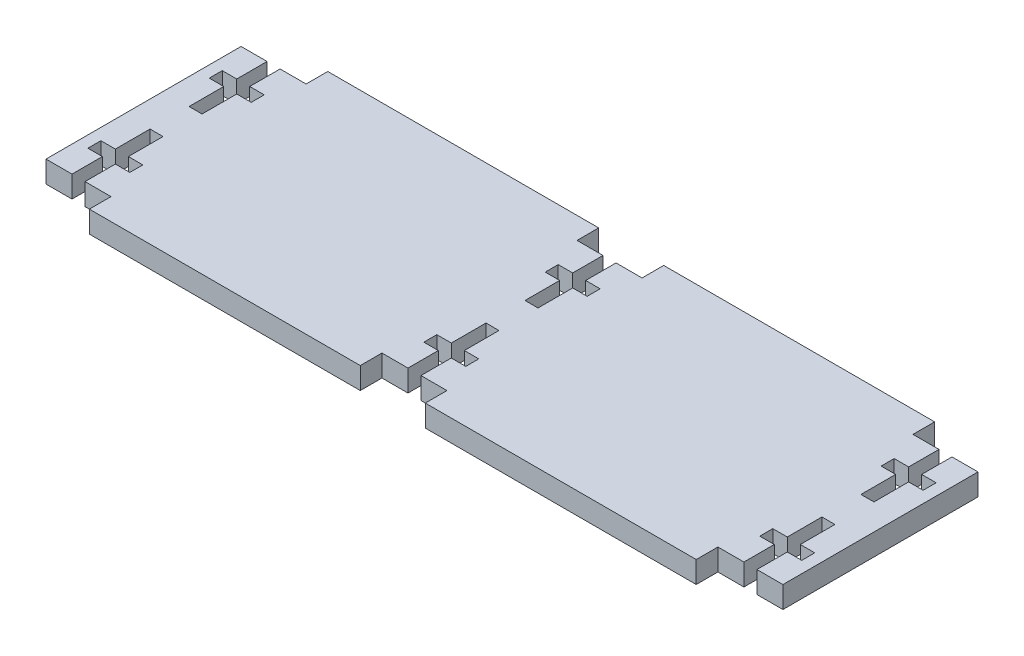
from build123d import *

# Parameters (mm, degrees)
SCHIZZO1_W                   = 170
SCHIZZO1_H                   = 55
ESTRUSIONE_ESTRUSIONE2_DEPTH = 5
SCHIZZO2_W                   = 15
SCHIZZO2_H                   = 5
TAGLIO_ESTRUSIONE1_DEPTH     = 6
TAGLIO_ESTRUSIONE3_DEPTH     = 6


with BuildPart() as part:
    # Schizzo1 → Estrusione-Estrusione2 (new body)
    with BuildSketch(Plane(origin=(0, 0, 0), x_dir=(1, 0, 0), z_dir=(0, 1, 0))):
        with Locations((30.43505086, -0.781075862)):
            Rectangle(SCHIZZO1_W, SCHIZZO1_H)
    extrude(amount=-ESTRUSIONE_ESTRUSIONE2_DEPTH)

    # Schizzo2 → Taglio-Estrusione1 (cut, through all)
    with BuildSketch(Plane(origin=(0, 0, 0), x_dir=(1, 0, 0), z_dir=(0, 1, 0))):
        with Locations((-47.06494914, -25.781075862)):
            Rectangle(SCHIZZO2_W, SCHIZZO2_H)
        with Locations((-47.06494914, 24.218924138)):
            Rectangle(SCHIZZO2_W, SCHIZZO2_H)
        with Locations((107.93505086, -25.781075862)):
            Rectangle(SCHIZZO2_W, SCHIZZO2_H)
        with Locations((107.93505086, 24.218924138)):
            Rectangle(SCHIZZO2_W, SCHIZZO2_H)
        with Locations((30.43505086, -25.781075862)):
            Rectangle(SCHIZZO2_W, SCHIZZO2_H)
        with Locations((30.43505086, 24.218924138)):
            Rectangle(SCHIZZO2_W, SCHIZZO2_H)
    extrude(amount=-TAGLIO_ESTRUSIONE1_DEPTH, mode=Mode.SUBTRACT)

    # Schizzo3 → Taglio-Estrusione3 (cut, through all)
    with BuildSketch(Plane(origin=(0, 0, 0), x_dir=(1, 0, 0), z_dir=(0, 1, 0))):
        Polygon((-48.56494914, -23.281075862), (-45.56494914, -23.281075862), (-45.56494914, -16.281075862), (-42.22494914, -16.281075862), (-42.22494914, -13.281075862), (-45.56494914, -13.281075862), (-45.56494914, -5.281075862), (-48.56494914, -5.281075862), (-48.56494914, -13.281075862), (-51.90494914, -13.281075862), (-51.90494914, -16.281075862), (-48.56494914, -16.281075862), align=None)
        Polygon((28.93505086, -23.281075862), (31.93505086, -23.281075862), (31.93505086, -16.281075862), (35.27505086, -16.281075862), (35.27505086, -13.281075862), (31.93505086, -13.281075862), (31.93505086, -5.281075862), (28.93505086, -5.281075862), (28.93505086, -13.281075862), (25.59505086, -13.281075862), (25.59505086, -16.281075862), (28.93505086, -16.281075862), align=None)
        Polygon((106.43505086, -23.281075862), (109.43505086, -23.281075862), (109.43505086, -16.281075862), (112.77505086, -16.281075862), (112.77505086, -13.281075862), (109.43505086, -13.281075862), (109.43505086, -5.281075862), (106.43505086, -5.281075862), (106.43505086, -13.281075862), (103.09505086, -13.281075862), (103.09505086, -16.281075862), (106.43505086, -16.281075862), align=None)
        Polygon((106.43505086, 3.718924138), (109.43505086, 3.718924138), (109.43505086, 11.718924138), (112.77505086, 11.718924138), (112.77505086, 14.718924138), (109.43505086, 14.718924138), (109.43505086, 21.718924138), (106.43505086, 21.718924138), (106.43505086, 14.718924138), (103.09505086, 14.718924138), (103.09505086, 11.718924138), (106.43505086, 11.718924138), align=None)
        Polygon((28.93505086, 3.718924138), (31.93505086, 3.718924138), (31.93505086, 11.718924138), (35.27505086, 11.718924138), (35.27505086, 14.718924138), (31.93505086, 14.718924138), (31.93505086, 21.718924138), (28.93505086, 21.718924138), (28.93505086, 14.718924138), (25.59505086, 14.718924138), (25.59505086, 11.718924138), (28.93505086, 11.718924138), align=None)
        Polygon((-48.56494914, 3.718924138), (-45.56494914, 3.718924138), (-45.56494914, 11.718924138), (-42.22494914, 11.718924138), (-42.22494914, 14.718924138), (-45.56494914, 14.718924138), (-45.56494914, 21.718924138), (-48.56494914, 21.718924138), (-48.56494914, 14.718924138), (-51.90494914, 14.718924138), (-51.90494914, 11.718924138), (-48.56494914, 11.718924138), align=None)
    extrude(amount=-TAGLIO_ESTRUSIONE3_DEPTH, mode=Mode.SUBTRACT)


solid = part.part
